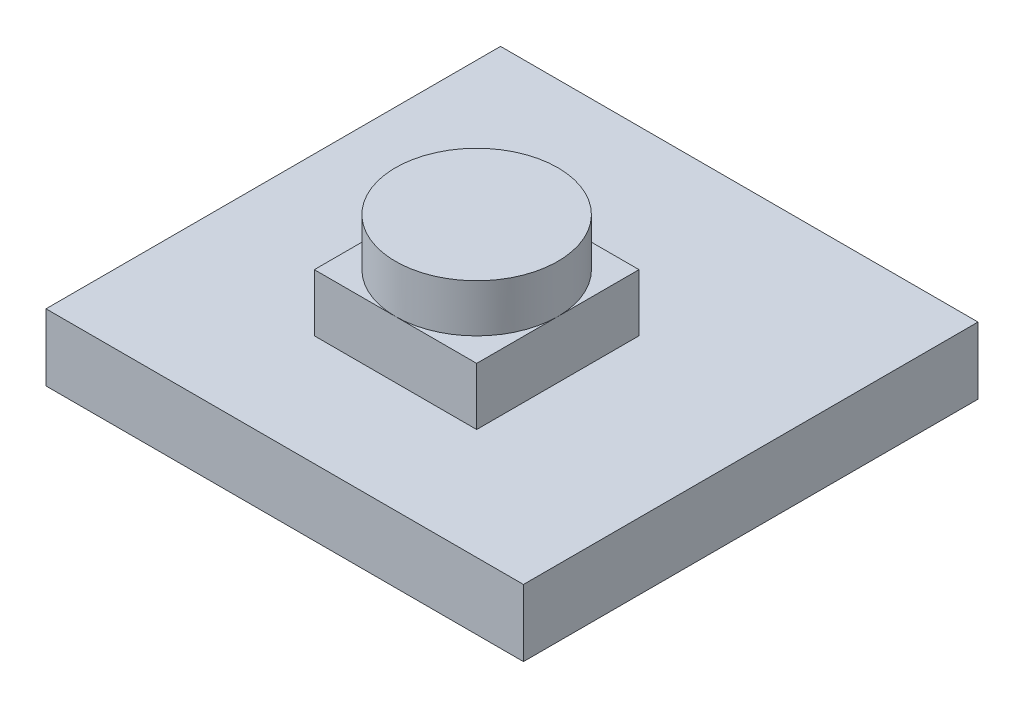
from build123d import *

# Parameters (mm, degrees)
SKETCH1_W           = 25
SKETCH1_H           = 23.8
BOSS_EXTRUDE1_DEPTH = 3.5
BOSS_EXTRUDE2_START = -3.5
SKETCH2_W           = 8.5
SKETCH2_H           = 8.5
BOSS_EXTRUDE2_DEPTH = 6.5
BOSS_EXTRUDE3_START = -6.5
SKETCH3_R           = 4.25
BOSS_EXTRUDE3_DEPTH = 9


with BuildPart() as part:
    # Sketch1 → Boss-Extrude1 (new body)
    with BuildSketch(Plane(origin=(0, 0, 0), x_dir=(1, 0, 0), z_dir=(0, 1, 0))):
        Rectangle(SKETCH1_W, SKETCH1_H)
    extrude(amount=BOSS_EXTRUDE1_DEPTH)

    # Sketch2 → Boss-Extrude2 (add)
    with BuildSketch(Plane(origin=(0, 3.5, 0), x_dir=(1, 0, 0), z_dir=(0, 1, 0)).offset(BOSS_EXTRUDE2_START)):
        with Locations((0, -1.85)):
            Rectangle(SKETCH2_W, SKETCH2_H)
    extrude(amount=BOSS_EXTRUDE2_DEPTH)

    # Sketch3 → Boss-Extrude3 (add)
    with BuildSketch(Plane(origin=(0, 6.5, 0), x_dir=(1, 0, 0), z_dir=(0, 1, 0)).offset(BOSS_EXTRUDE3_START)):
        with Locations((0, -1.85)):
            Circle(SKETCH3_R)
    extrude(amount=BOSS_EXTRUDE3_DEPTH)


solid = part.part
